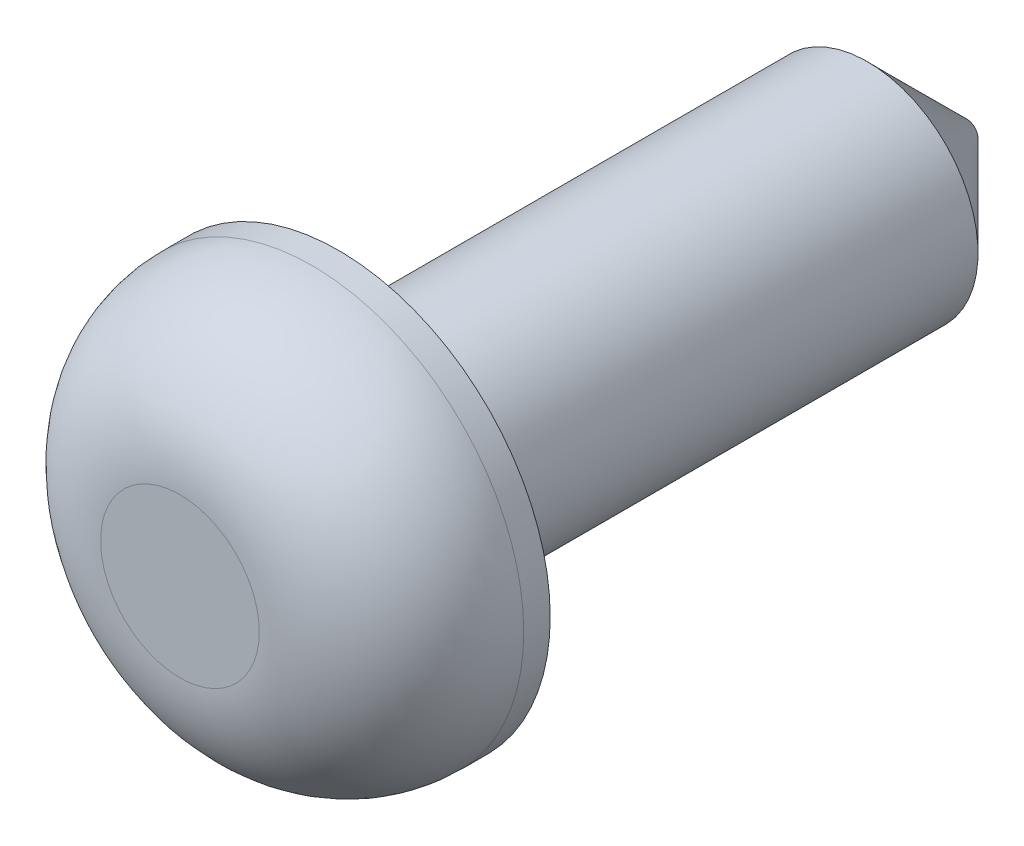
from build123d import *

# Parameters (mm, degrees)
SKETCH1_R           = 4.064
BOSS_EXTRUDE1_DEPTH = 3.048
SKETCH2_R           = 2.1209
BOSS_EXTRUDE2_DEPTH = 12.065
CHAMFER1_SIZE       = 1.905
FILLET1_R           = 2.54


with BuildPart() as part:
    # Sketch1 → Boss-Extrude1 (new body)
    with BuildSketch(Plane.XY):
        Circle(SKETCH1_R)
    extrude(amount=BOSS_EXTRUDE1_DEPTH)

    # Sketch2 → Boss-Extrude2 (add)
    with BuildSketch(Plane(origin=(0, 0, 0), x_dir=(-1, 0, 0), z_dir=(0, 0, -1))):
        Circle(SKETCH2_R)
    extrude(amount=BOSS_EXTRUDE2_DEPTH)

    # Chamfer1
    chamfer1_edges = [part.edges().sort_by_distance(p)[0] for p in [
        (2.1209, 0, -12.065),
    ]]
    chamfer(chamfer1_edges, length=CHAMFER1_SIZE)

    # Fillet1
    fillet1_edges = [part.edges().sort_by_distance(p)[0] for p in [
        (-4.064, 0, 3.048),
    ]]
    fillet(fillet1_edges, radius=FILLET1_R)


solid = part.part
